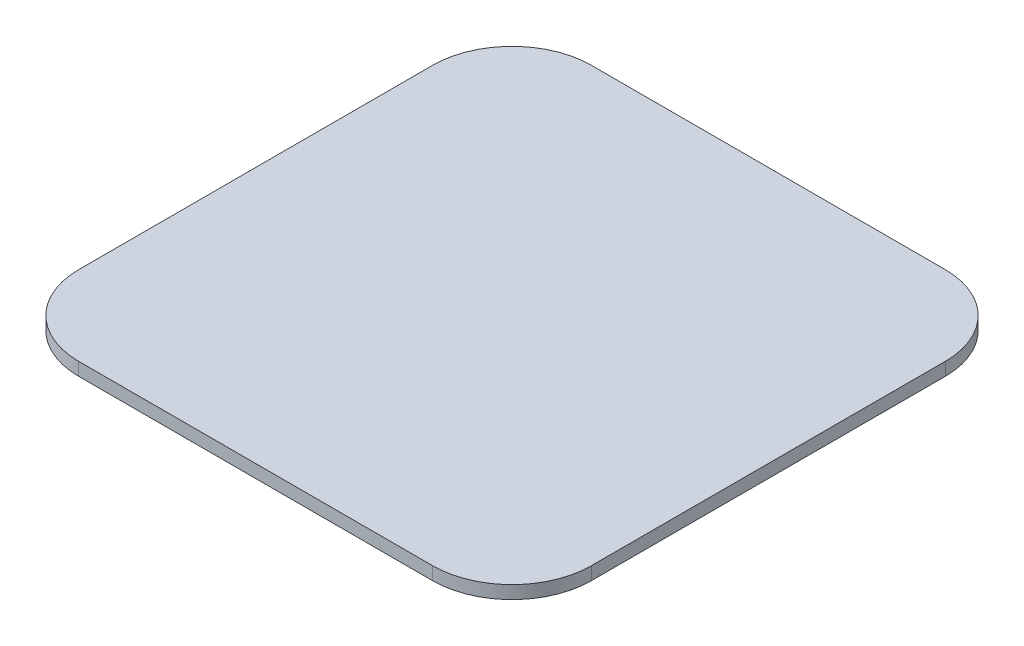
from build123d import *

# Parameters (mm, degrees)
BOSS_EXTRUDE1_DEPTH = 1.8


with BuildPart() as part:
    # Sketch1 → Boss-Extrude1 (new body)
    with BuildSketch(Plane(origin=(0, 0, 0), x_dir=(1, 0, 0), z_dir=(0, 1, 0))):
        with BuildLine():
            Line((24.5, -35.5), (-24.5, -35.5))
            ThreePointArc((-24.5, -35.5), (-32.278174593, -32.278174593), (-35.5, -24.5))
            Line((-35.5, -24.5), (-35.5, 24.5))
            ThreePointArc((-35.5, 24.5), (-32.278174593, 32.278174593), (-24.5, 35.5))
            Line((-24.5, 35.5), (24.5, 35.5))
            ThreePointArc((24.5, 35.5), (32.278174593, 32.278174593), (35.5, 24.5))
            Line((35.5, 24.5), (35.5, -24.5))
            ThreePointArc((35.5, -24.5), (32.278174593, -32.278174593), (24.5, -35.5))
        make_face()
    extrude(amount=BOSS_EXTRUDE1_DEPTH)


solid = part.part
